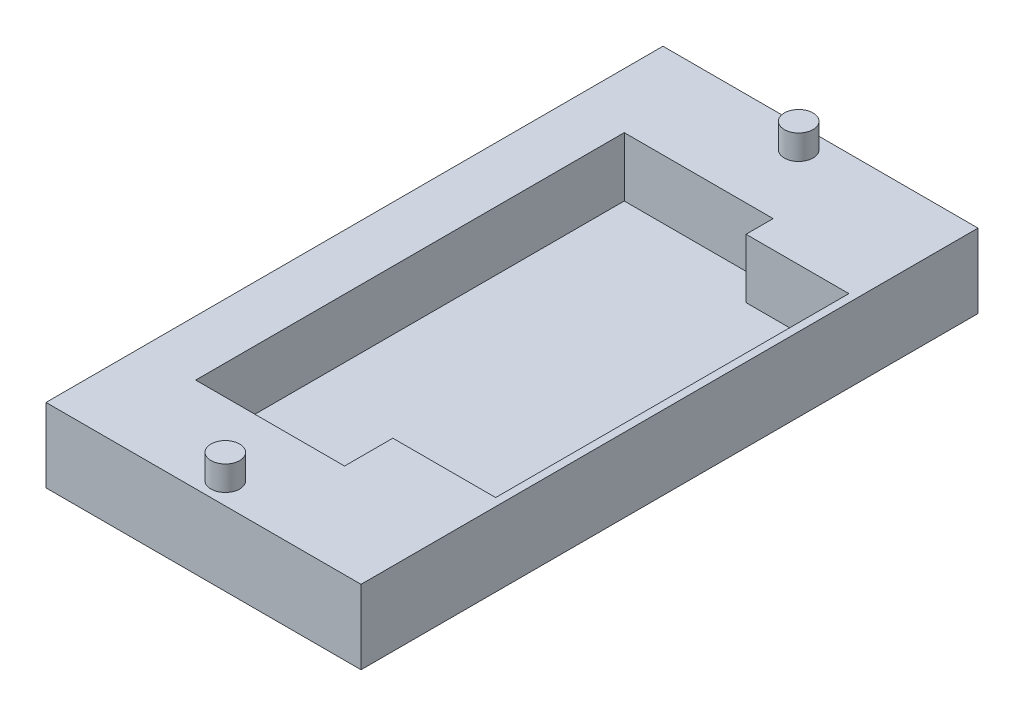
from build123d import *

# Parameters (mm, degrees)
CROQUIS1_W              = 45
CROQUIS1_H              = 75
SALIENTE_EXTRUIR1_DEPTH = 9
CROQUIS2_W              = 18.1
CROQUIS2_H              = 52.1
CROQUIS2_W_2            = 12.5
CROQUIS2_H_2            = 42.938951505
CORTAR_EXTRUIR9_DEPTH   = 7.2
CROQUIS3_W              = 6.70437092
CROQUIS3_H              = 75
CORTAR_EXTRUIR10_DEPTH  = 9
CROQUIS4_R              = 1.745
CROQUIS4_R_2            = 1.75
SALIENTE_EXTRUIR2_DEPTH = 3


with BuildPart() as part:
    # Croquis1 → Saliente-Extruir1 (new body)
    with BuildSketch(Plane(origin=(0, 0, 0), x_dir=(1, 0, 0), z_dir=(0, 1, 0))):
        Rectangle(CROQUIS1_W, CROQUIS1_H)
    extrude(amount=SALIENTE_EXTRUIR1_DEPTH)

    # Croquis2 → Cortar-Extruir9 (cut)
    with BuildSketch(Plane(origin=(0, 9, 0), x_dir=(1, 0, 0), z_dir=(0, 1, 0))):
        Rectangle(CROQUIS2_W, CROQUIS2_H)
        with Locations((15.3, 1.284934341)):
            Rectangle(CROQUIS2_W_2, CROQUIS2_H_2)
    extrude(amount=-CORTAR_EXTRUIR9_DEPTH, mode=Mode.SUBTRACT)

    # Croquis3 → Cortar-Extruir10 (cut)
    with BuildSketch(Plane(origin=(0, 9, 0), x_dir=(1, 0, 0), z_dir=(0, 1, 0))):
        with Locations((-19.14781454, 0)):
            Rectangle(CROQUIS3_W, CROQUIS3_H)
    extrude(amount=-CORTAR_EXTRUIR10_DEPTH, mode=Mode.SUBTRACT)

    # Croquis4 → Saliente-Extruir2 (add)
    with BuildSketch(Plane(origin=(0, 9, 0), x_dir=(1, 0, 0), z_dir=(0, 1, 0))):
        with Locations((3.35218546, -34.85)):
            Circle(CROQUIS4_R)
        with Locations((3.35218546, 34.85)):
            Circle(CROQUIS4_R_2)
    extrude(amount=SALIENTE_EXTRUIR2_DEPTH)


solid = part.part
